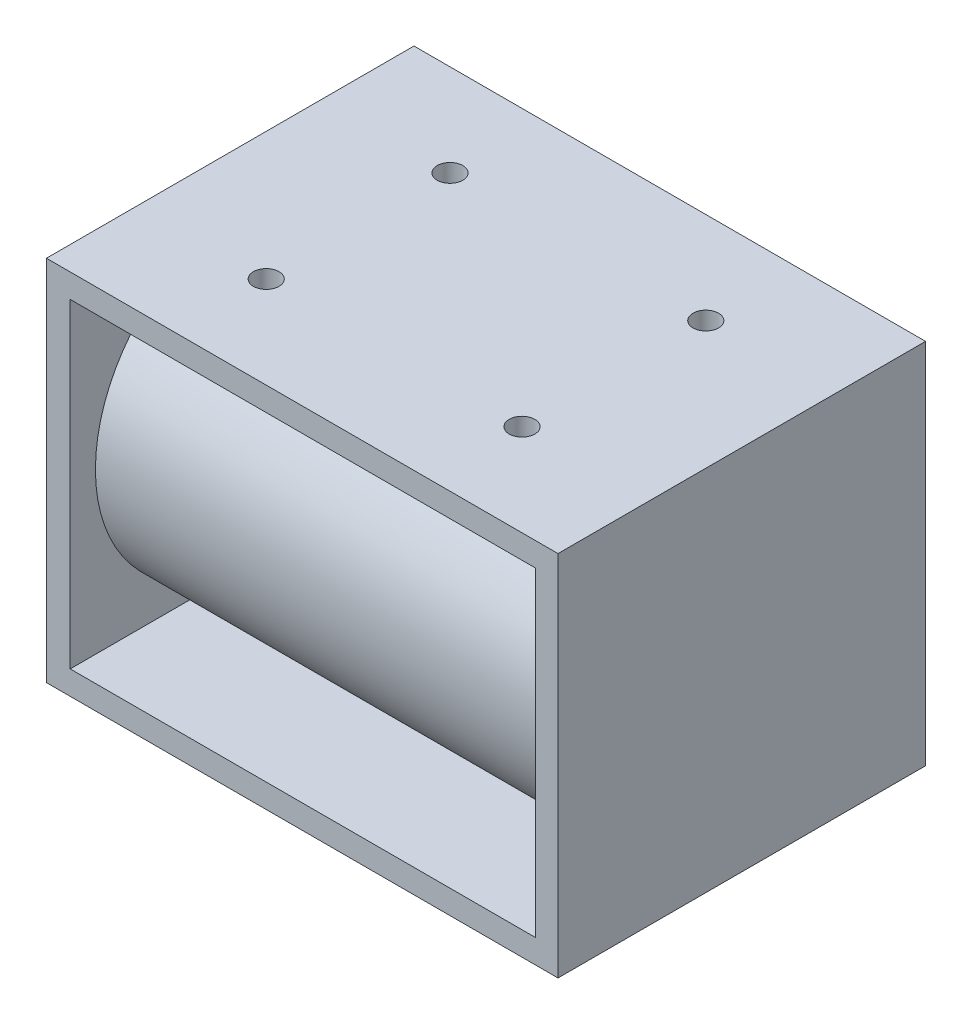
from build123d import *

# Parameters (mm, degrees)
SKETCH1_W           = 50.8
SKETCH1_H           = 36.4998
SKETCH1_W_2         = 46.203262774
SKETCH1_H_2         = 31.7754
BOSS_EXTRUDE1_DEPTH = 36.4998
SKETCH8_R           = 15.748
BOSS_EXTRUDE3_DEPTH = 46.0756
SKETCH9_R           = 5.5499
CUT_EXTRUDE1_DEPTH  = 25.4
CUT_EXTRUDE2_REACH  = 38.5
SKETCH10_R          = 1.27


with BuildPart() as part:
    # Sketch1 → Boss-Extrude1 (new body)
    with BuildSketch(Plane.XY):
        with Locations((25.4, 18.2499)):
            Rectangle(SKETCH1_W, SKETCH1_H)
        with Locations((25.463831387, 18.2499)):
            Rectangle(SKETCH1_W_2, SKETCH1_H_2, mode=Mode.SUBTRACT)
    extrude(amount=BOSS_EXTRUDE1_DEPTH)

    # Sketch8 → Boss-Extrude3 (add)
    with BuildSketch(Plane(origin=(2.3622, 0, 0), x_dir=(0, 0, -1), z_dir=(1, 0, 0))):
        with Locations((-18.2499, 18.2499)):
            Circle(SKETCH8_R)
    extrude(amount=BOSS_EXTRUDE3_DEPTH)

    # Sketch9 → Cut-Extrude1 (cut)
    with BuildSketch(Plane.ZY):
        with Locations((18.2499, 18.2499)):
            Circle(SKETCH9_R)
    extrude(amount=-CUT_EXTRUDE1_DEPTH, mode=Mode.SUBTRACT)

    # Sketch10 → Cut-Extrude2 (cut, up to next)
    with BuildSketch(Plane(origin=(0, 36.4998, 0), x_dir=(1, 0, 0), z_dir=(0, 1, 0)), mode=Mode.PRIVATE) as cut_extrude2_sk1:
        with Locations((38.1, -9.12495)):
            Circle(SKETCH10_R)
    cut_extrude2_tool1 = extrude(cut_extrude2_sk1.sketch, amount=-CUT_EXTRUDE2_REACH, mode=Mode.PRIVATE) & part.part
    add(cut_extrude2_tool1.solids().sort_by_distance((38.1, 36.4998, 9.12495))[0], mode=Mode.SUBTRACT)
    # Sketch10 → Cut-Extrude2 (cut, up to next)
    with BuildSketch(Plane(origin=(0, 36.4998, 0), x_dir=(1, 0, 0), z_dir=(0, 1, 0)), mode=Mode.PRIVATE) as cut_extrude2_sk2:
        with Locations((12.7, -9.12495)):
            Circle(SKETCH10_R)
    cut_extrude2_tool2 = extrude(cut_extrude2_sk2.sketch, amount=-CUT_EXTRUDE2_REACH, mode=Mode.PRIVATE) & part.part
    add(cut_extrude2_tool2.solids().sort_by_distance((12.7, 36.4998, 9.12495))[0], mode=Mode.SUBTRACT)
    # Sketch10 → Cut-Extrude2 (cut, up to next)
    with BuildSketch(Plane(origin=(0, 36.4998, 0), x_dir=(1, 0, 0), z_dir=(0, 1, 0)), mode=Mode.PRIVATE) as cut_extrude2_sk3:
        with Locations((38.1, -27.37485)):
            Circle(SKETCH10_R)
    cut_extrude2_tool3 = extrude(cut_extrude2_sk3.sketch, amount=-CUT_EXTRUDE2_REACH, mode=Mode.PRIVATE) & part.part
    add(cut_extrude2_tool3.solids().sort_by_distance((38.1, 36.4998, 27.37485))[0], mode=Mode.SUBTRACT)
    # Sketch10 → Cut-Extrude2 (cut, up to next)
    with BuildSketch(Plane(origin=(0, 36.4998, 0), x_dir=(1, 0, 0), z_dir=(0, 1, 0)), mode=Mode.PRIVATE) as cut_extrude2_sk4:
        with Locations((12.7, -27.37485)):
            Circle(SKETCH10_R)
    cut_extrude2_tool4 = extrude(cut_extrude2_sk4.sketch, amount=-CUT_EXTRUDE2_REACH, mode=Mode.PRIVATE) & part.part
    add(cut_extrude2_tool4.solids().sort_by_distance((12.7, 36.4998, 27.37485))[0], mode=Mode.SUBTRACT)


solid = part.part
